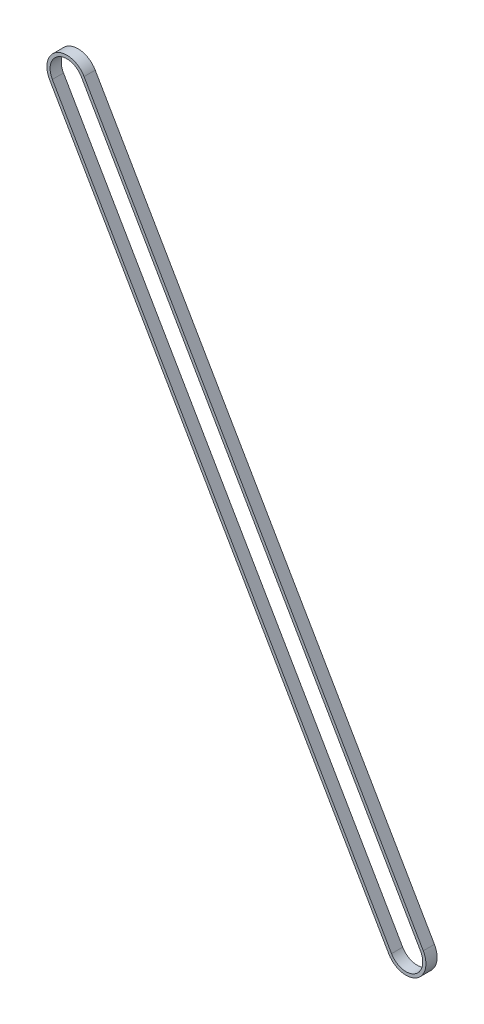
from build123d import *

# Parameters (mm, degrees)
EXTRUDE_THIN1_DEPTH = 7


with BuildPart() as part:
    # Sketch2 → Extrude-Thin1 (new body)
    with BuildSketch(Plane.XY):
        with BuildLine():
            Line((-202.024682453, 374.917014391), (10.825317547, 6.25))
            ThreePointArc((10.825317547, 6.25), (6.25, -10.825317547), (-10.825317547, -6.25))
            Line((-10.825317547, -6.25), (-223.675317547, 362.417014391))
            ThreePointArc((-223.675317547, 362.417014391), (-219.1, 379.492331938), (-202.024682453, 374.917014391))
        make_face()
        with BuildLine():
            Line((-203.75673326, 373.917014391), (9.09326674, 5.25))
            ThreePointArc((9.09326674, 5.25), (5.25, -9.09326674), (-9.09326674, -5.25))
            Line((-9.09326674, -5.25), (-221.94326674, 363.417014391))
            ThreePointArc((-221.94326674, 363.417014391), (-218.1, 377.760281131), (-203.75673326, 373.917014391))
        make_face(mode=Mode.SUBTRACT)
    extrude(amount=EXTRUDE_THIN1_DEPTH)


solid = part.part
